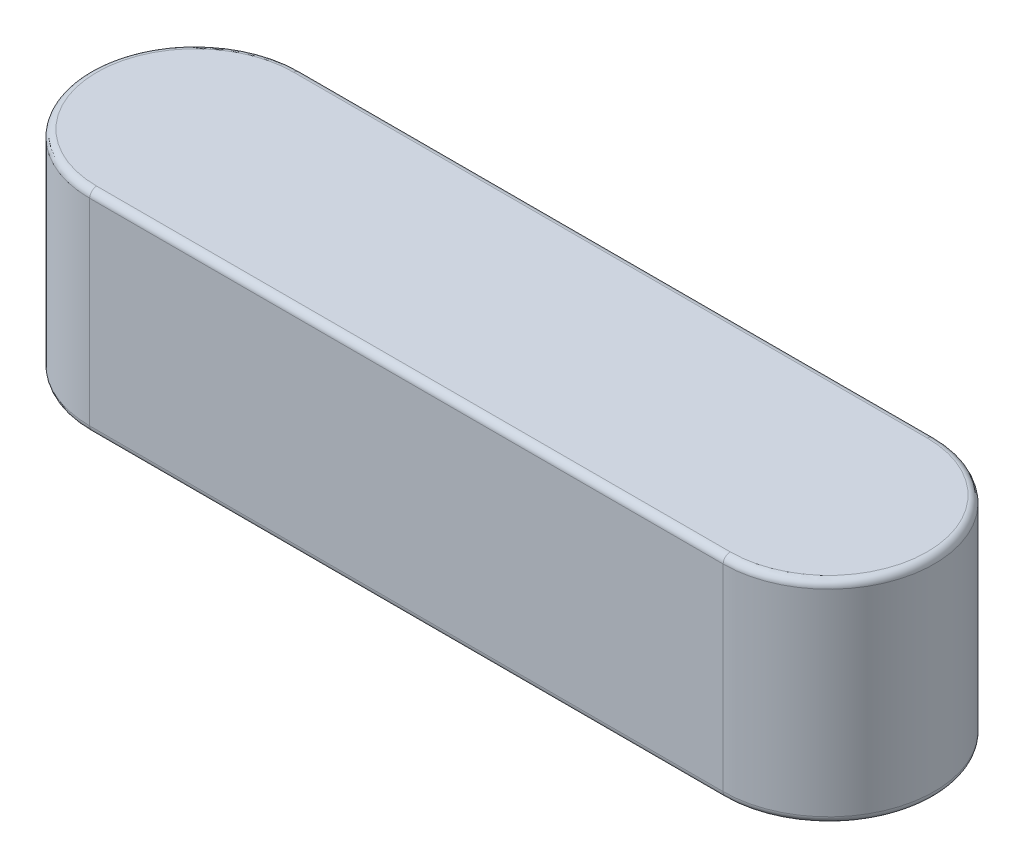
from build123d import *

# Parameters (mm, degrees)
BOSS_EXTRU_1_DEPTH = 3
CONG_1_R           = 0.1


with BuildPart() as part:
    # Esquisse1 → Boss.-Extru.1 (new body)
    with BuildSketch(Plane(origin=(0, 0, 0), x_dir=(1, 0, 0), z_dir=(0, 1, 0))):
        with BuildLine():
            Line((4.5, -1.5), (-4.5, -1.5))
            ThreePointArc((-4.5, -1.5), (-6, 0), (-4.5, 1.5))
            Line((-4.5, 1.5), (4.5, 1.5))
            ThreePointArc((4.5, 1.5), (6, 0), (4.5, -1.5))
        make_face()
    extrude(amount=BOSS_EXTRU_1_DEPTH)

    # Congé1
    cong_1_edges = [part.edges().sort_by_distance(p)[0] for p in [
        (-6, 3, 0),
        (0, 3, 1.5),
        (6, 3, 0),
        (0, 0, 1.5),
        (-6, 0, 0),
        (0, 0, -1.5),
        (6, 0, 0),
        (0, 3, -1.5),
    ]]
    fillet(cong_1_edges, radius=CONG_1_R)


solid = part.part
